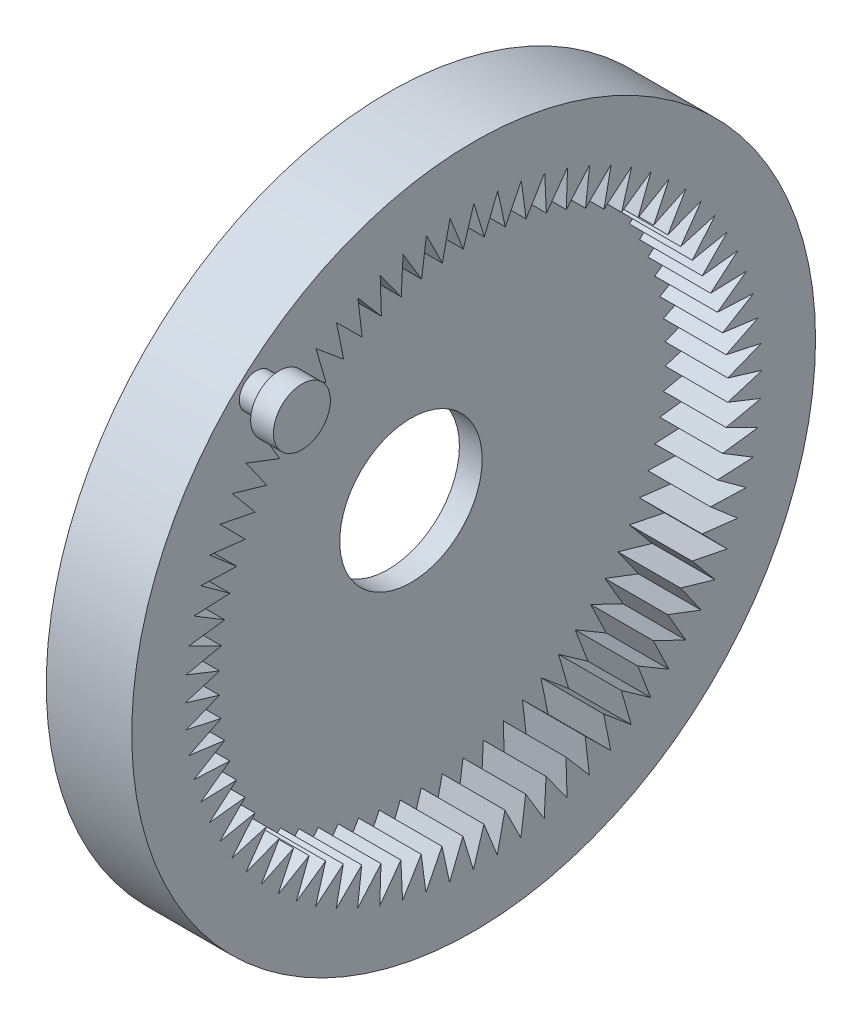
from build123d import *

# Parameters (mm, degrees)
SKETCH1_R           = 30
BOSS_EXTRUDE1_DEPTH = 7.5
CUT_EXTRUDE2_DEPTH  = 5.5
SKETCH6_R           = 6.25
CUT_EXTRUDE3_DEPTH  = 3
SKETCH9_R           = 1.5
BOSS_EXTRUDE5_DEPTH = 2
SKETCH10_R          = 2.5
BOSS_EXTRUDE6_DEPTH = 2


with BuildPart() as part:
    # Sketch1 → Boss-Extrude1 (new body)
    with BuildSketch(Plane(origin=(0, 0, 0), x_dir=(0, 0, -1), z_dir=(1, 0, 0))):
        Circle(SKETCH1_R)
    extrude(amount=BOSS_EXTRUDE1_DEPTH)

    # Sketch4 → Cut-Extrude2 (cut)
    with BuildSketch(Plane(origin=(7.5, 0, 0), x_dir=(0, -1, 0), z_dir=(1, 0, 0))):
        Polygon((8.200315972, -23.949003355), (8.095646912, -20.796423541), (10.150000757, -23.190028641), (9.785351218, -20.056859988), (12.030350745, -22.272642516), (11.408211652, -19.180287743), (13.828521239, -21.20311166), (12.953142433, -18.172694685), (15.532228911, -19.988742051), (14.409590118, -17.040963696), (17.12983571, -18.637829065), (15.76760569, -15.792825644), (18.610428362, -17.159600809), (17.017912527, -14.43680658), (19.963892917, -15.564155079), (18.151969766, -12.982169489), (21.18098384, -13.862390389), (19.162030646, -11.438851016), (22.253387167, -12.065931515), (20.041195426, -9.817393592), (23.173777294, -10.187050095), (20.78345852, -8.128873414), (23.935867025, -8.238580793), (21.383749518, -6.384824789), (24.534450513, -6.233833631), (21.837967824, -4.597161336), (24.965438827, -4.186503063), (22.143010666, -2.77809461), (25.225887879, -2.110574435), (22.296794293, -0.940050681), (25.314018538, -0.020228443), (22.298268206, 0.904414747), (25.229228782, 2.070255729), (22.147422337, 2.742702106), (24.972097812, 4.146597956), (21.845287117, 4.562254028), (24.544382092, 6.194614714), (21.393926434, 6.350641129), (23.949003355, 8.200315972), (20.796423541, 8.095646912), (23.190028641, 10.150000757), (20.056859988, 9.785351218), (22.272642516, 12.030350745), (19.180287743, 11.408211652), (21.20311166, 13.828521239), (18.172694685, 12.953142433), (19.988742051, 15.532228911), (17.040963696, 14.409590118), (18.637829065, 17.12983571), (15.792825644, 15.76760569), (17.159600809, 18.610428362), (14.43680658, 17.017912527), (15.564155079, 19.963892917), (12.982169489, 18.151969766), (13.862390389, 21.18098384), (11.438851016, 19.162030646), (12.065931515, 22.253387167), (9.817393592, 20.041195426), (10.187050095, 23.173777294), (8.128873414, 20.78345852), (8.238580793, 23.935867025), (6.384824789, 21.383749518), (6.233833631, 24.534450513), (4.597161336, 21.837967824), (4.186503063, 24.965438827), (2.77809461, 22.143010666), (2.110574435, 25.225887879), (0.940050681, 22.296794293), (0.020228443, 25.314018538), (-0.904414747, 22.298268206), (-2.070255729, 25.229228782), (-2.742702106, 22.147422337), (-4.146597956, 24.972097812), (-4.562254028, 21.845287117), (-6.194614714, 24.544382092), (-6.350641129, 21.393926434), (-8.200315972, 23.949003355), (-8.095646912, 20.796423541), (-10.150000757, 23.190028641), (-9.785351218, 20.056859988), (-12.030350745, 22.272642516), (-11.408211652, 19.180287743), (-13.828521239, 21.20311166), (-12.953142433, 18.172694685), (-15.532228911, 19.988742051), (-14.409590118, 17.040963696), (-17.12983571, 18.637829065), (-15.76760569, 15.792825644), (-18.610428362, 17.159600809), (-17.017912527, 14.43680658), (-19.963892917, 15.564155079), (-18.151969766, 12.982169489), (-21.18098384, 13.862390389), (-19.162030646, 11.438851016), (-22.253387167, 12.065931515), (-20.041195426, 9.817393592), (-23.173777294, 10.187050095), (-20.78345852, 8.128873414), (-23.935867025, 8.238580793), (-21.383749518, 6.384824789), (-24.534450513, 6.233833631), (-21.837967824, 4.597161336), (-24.965438827, 4.186503063), (-22.143010666, 2.77809461), (-25.225887879, 2.110574435), (-22.296794293, 0.940050681), (-25.314018538, 0.020228443), (-22.298268206, -0.904414747), (-25.229228782, -2.070255729), (-22.147422337, -2.742702106), (-24.972097812, -4.146597956), (-21.845287117, -4.562254028), (-24.544382092, -6.194614714), (-21.393926434, -6.350641129), (-23.949003355, -8.200315972), (-20.796423541, -8.095646912), (-23.190028641, -10.150000757), (-20.056859988, -9.785351218), (-22.272642516, -12.030350745), (-19.180287743, -11.408211652), (-21.20311166, -13.828521239), (-18.172694685, -12.953142433), (-19.988742051, -15.532228911), (-17.040963696, -14.409590118), (-18.637829065, -17.12983571), (-15.792825644, -15.76760569), (-17.159600809, -18.610428362), (-14.43680658, -17.017912527), (-15.564155079, -19.963892917), (-12.982169489, -18.151969766), (-13.862390389, -21.18098384), (-11.438851016, -19.162030646), (-12.065931515, -22.253387167), (-9.817393592, -20.041195426), (-10.187050095, -23.173777294), (-8.128873414, -20.78345852), (-8.238580793, -23.935867025), (-6.384824789, -21.383749518), (-6.233833631, -24.534450513), (-4.597161336, -21.837967824), (-4.186503063, -24.965438827), (-2.77809461, -22.143010666), (-2.110574435, -25.225887879), (-0.940050681, -22.296794293), (-0.020228443, -25.314018538), (0.904414747, -22.298268206), (2.070255729, -25.229228782), (2.742702106, -22.147422337), (4.146597956, -24.972097812), (4.562254028, -21.845287117), (6.194614714, -24.544382092), (6.350641129, -21.393926434), align=None)
    extrude(amount=-CUT_EXTRUDE2_DEPTH, mode=Mode.SUBTRACT)

    # Sketch6 → Cut-Extrude3 (cut, through all)
    with BuildSketch(Plane(origin=(2, 0, 0), x_dir=(0, 0, -1), z_dir=(1, 0, 0))):
        Circle(SKETCH6_R)
    extrude(amount=-CUT_EXTRUDE3_DEPTH, mode=Mode.SUBTRACT)

    # Sketch9 → Boss-Extrude5 (add)
    with BuildSketch(Plane(origin=(7.5, 0, 0), x_dir=(0, 0, -1), z_dir=(1, 0, 0))):
        with Locations((-19.065690414, 20.634386461)):
            Circle(SKETCH9_R)
    extrude(amount=BOSS_EXTRUDE5_DEPTH)

    # Sketch10 → Boss-Extrude6 (add)
    with BuildSketch(Plane(origin=(9.5, 0, 0), x_dir=(0, 0, -1), z_dir=(1, 0, 0))):
        with Locations((-19.065690414, 20.634386461)):
            Circle(SKETCH10_R)
    extrude(amount=BOSS_EXTRUDE6_DEPTH)


solid = part.part
